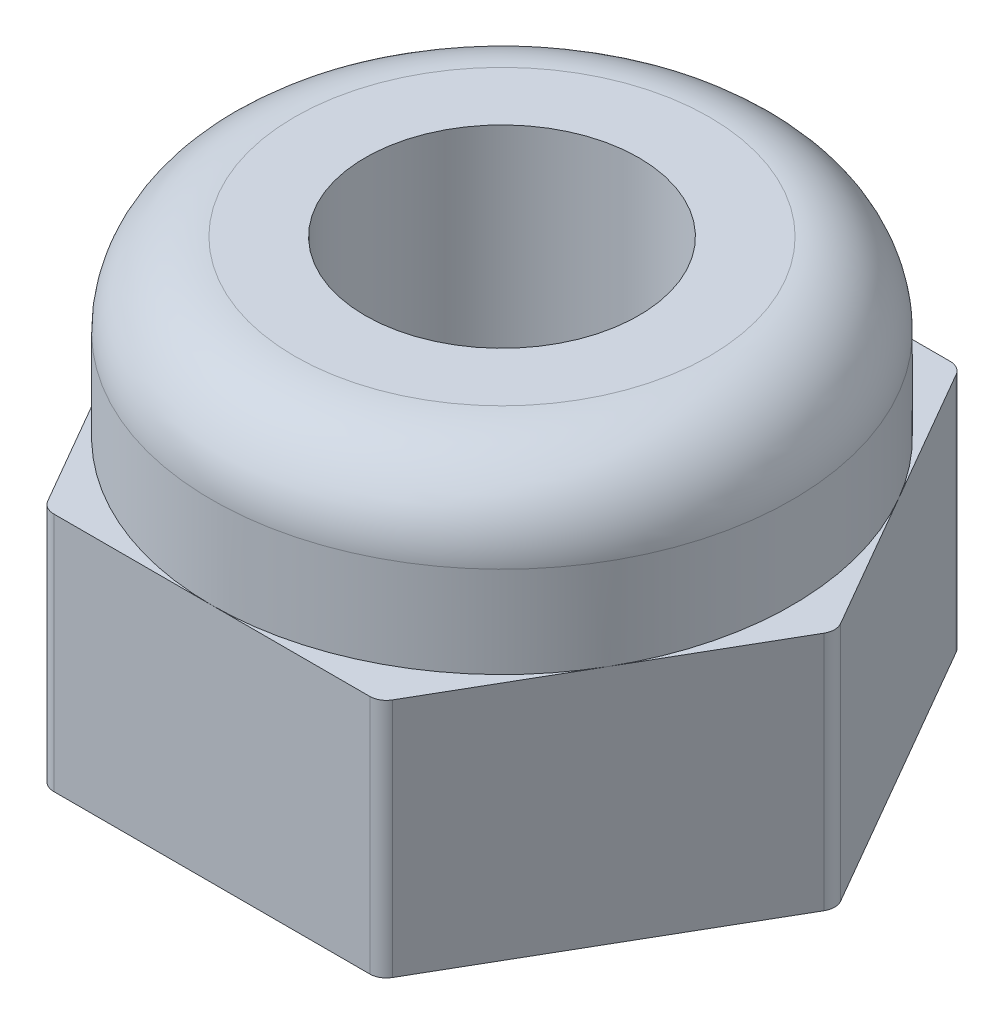
from build123d import *

# Parameters (mm, degrees)
BOSS_EXTRUDE1_DEPTH = 2.9
SKETCH2_R           = 3.5
BOSS_EXTRUDE2_DEPTH = 5
FILLET1_R           = 1
FILLET2_R           = 0.2
M4_TAPPED_HOLE1_D   = 3.3


with BuildPart() as part:
    # Sketch1 → Boss-Extrude1 (new body)
    with BuildSketch(Plane(origin=(0, 0, 0), x_dir=(1, 0, 0), z_dir=(0, 1, 0))):
        Polygon((4.041451884, 0), (2.020725942, 3.5), (-2.020725942, 3.5), (-4.041451884, 0), (-2.020725942, -3.5), (2.020725942, -3.5), align=None)
    extrude(amount=BOSS_EXTRUDE1_DEPTH)

    # Sketch2 → Boss-Extrude2 (add)
    with BuildSketch(Plane.XZ):
        Circle(SKETCH2_R)
    extrude(amount=-BOSS_EXTRUDE2_DEPTH)

    # Fillet1
    fillet1_edges = [part.edges().sort_by_distance(p)[0] for p in [
        (-3.5, 5, 0),
    ]]
    fillet(fillet1_edges, radius=FILLET1_R)

    # Fillet2
    fillet2_edges = [part.edges().sort_by_distance(p)[0] for p in [
        (2.020725942, 1.45, 3.5),
        (-2.020725942, 1.45, 3.5),
        (-4.041451884, 1.45, 0),
        (-2.020725942, 1.45, -3.5),
        (2.020725942, 1.45, -3.5),
        (4.041451884, 1.45, 0),
    ]]
    fillet(fillet2_edges, radius=FILLET2_R)

    # M4 Tapped Hole1 (through all)
    with Locations(Plane(origin=(0, 0, 0), x_dir=(-1, 0, 0), z_dir=(0, -1, 0))):
        with Locations((0, 0)):
            Hole(M4_TAPPED_HOLE1_D / 2)


solid = part.part
